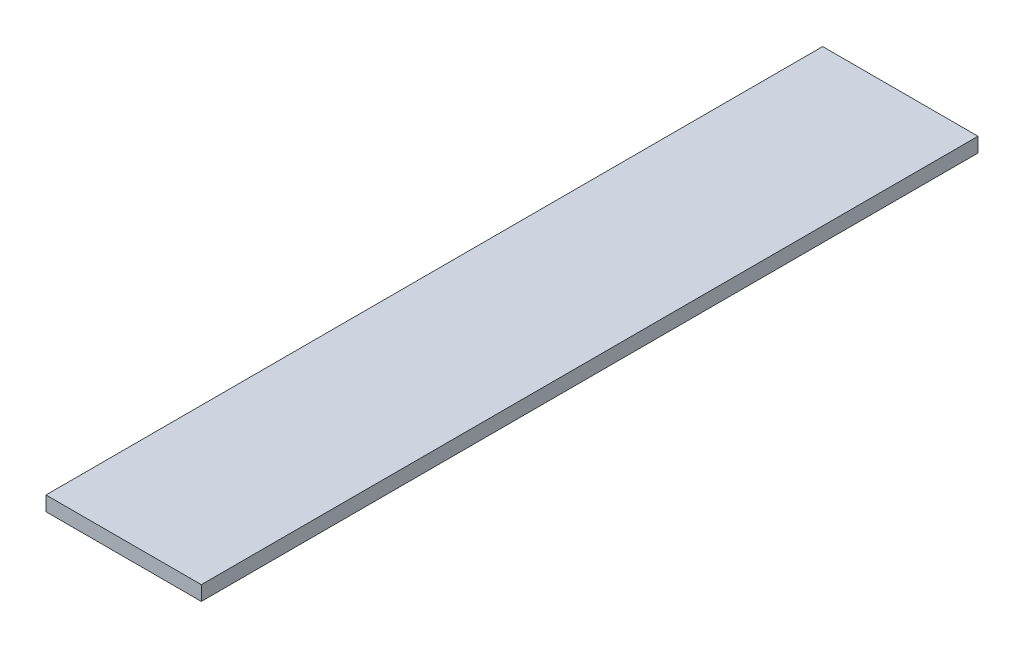
from build123d import *

# Parameters (mm, degrees)
SKETCH1_W           = 50.8
SKETCH1_H           = 254
BOSS_EXTRUDE1_DEPTH = 4.7625


with BuildPart() as part:
    # Sketch1 → Boss-Extrude1 (new body)
    with BuildSketch(Plane(origin=(0, 0, 0), x_dir=(1, 0, 0), z_dir=(0, 1, 0))):
        with Locations((25.4, -127)):
            Rectangle(SKETCH1_W, SKETCH1_H)
    extrude(amount=BOSS_EXTRUDE1_DEPTH)


solid = part.part
